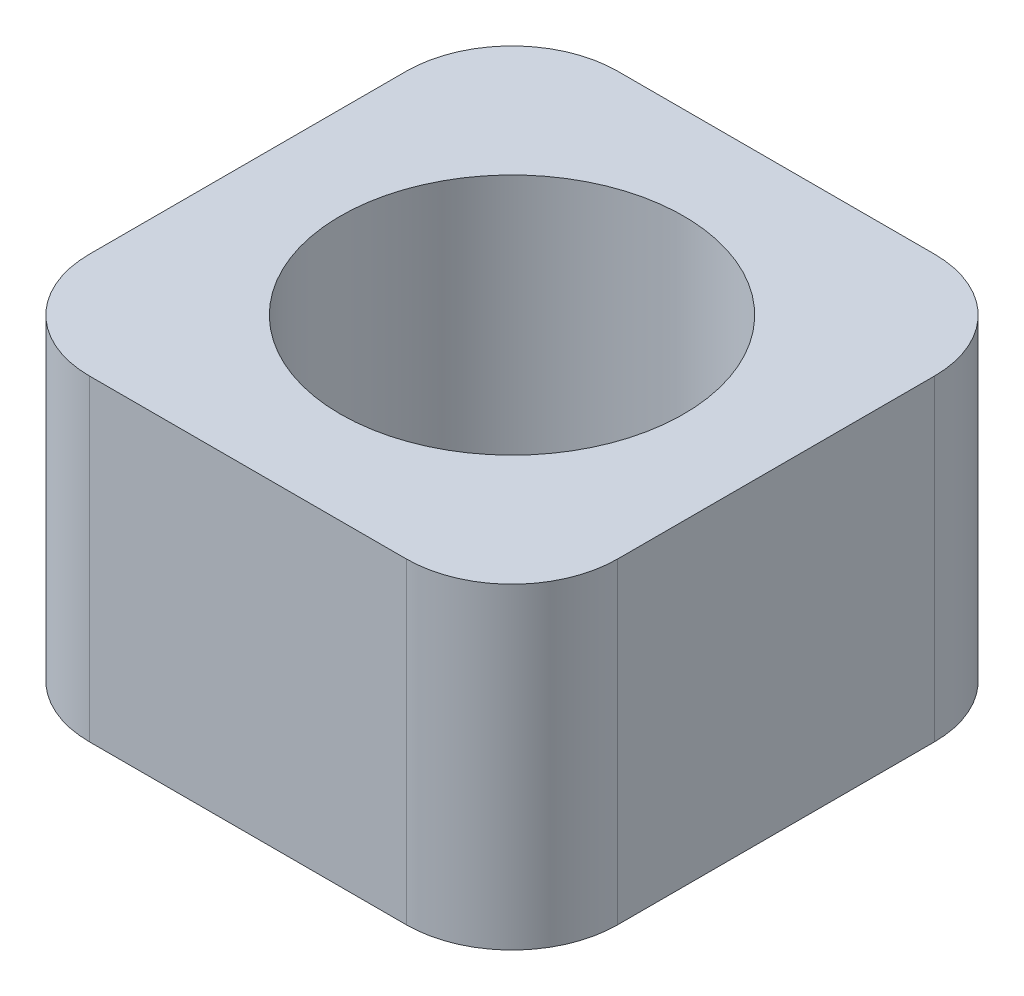
from build123d import *

# Parameters (mm, degrees)
SKETCH1_R           = 5
SKETCH1_R_2         = 3.25
BOSS_EXTRUDE1_DEPTH = 3
FILLET1_R           = 2


with BuildPart() as part:
    # Sketch1 → Boss-Extrude1 (new body, symmetric)
    with BuildSketch(Plane(origin=(0, 0, 0), x_dir=(1, 0, 0), z_dir=(0, 1, 0))):
        with BuildLine():
            Line((-5, 5), (-5, 0))
            ThreePointArc((-5, 0), (-3.535533906, 3.535533906), (0, 5))
            Line((0, 5), (-5, 5))
        make_face()
        Circle(SKETCH1_R)
        Circle(SKETCH1_R_2, mode=Mode.SUBTRACT)
        with BuildLine():
            ThreePointArc((0, 5), (3.535533906, 3.535533906), (5, 0))
            Line((5, 0), (5, 5))
            Line((5, 5), (0, 5))
        make_face()
        with BuildLine():
            ThreePointArc((5, 0), (3.535533906, -3.535533906), (0, -5))
            Line((0, -5), (5, -5))
            Line((5, -5), (5, 0))
        make_face()
        with BuildLine():
            Line((-5, 0), (-5, -5))
            Line((-5, -5), (0, -5))
            ThreePointArc((0, -5), (-3.535533906, -3.535533906), (-5, 0))
        make_face()
    extrude(amount=BOSS_EXTRUDE1_DEPTH, both=True)

    # Fillet1
    fillet1_edges = [part.edges().sort_by_distance(p)[0] for p in [
        (-5, 0, -5),
        (5, 0, -5),
        (5, 0, 5),
        (-5, 0, 5),
    ]]
    fillet(fillet1_edges, radius=FILLET1_R)


solid = part.part
